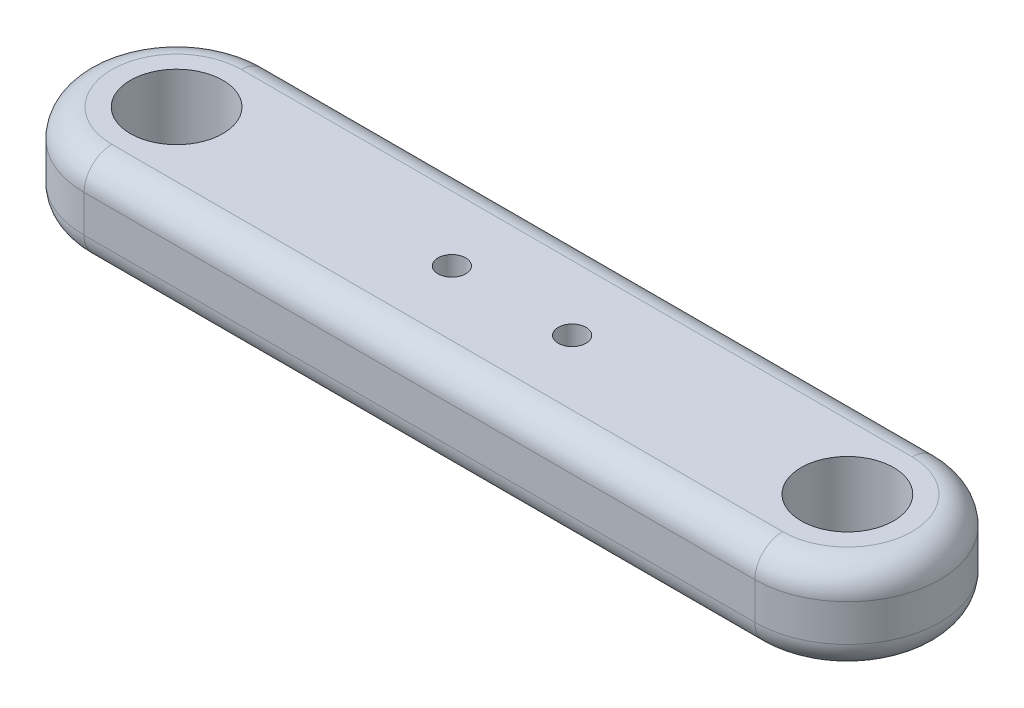
from build123d import *

# Parameters (mm, degrees)
SKETCH2_R           = 5
BOSS_EXTRUDE1_DEPTH = 10
FILLET1_R           = 3
BOSS_EXTRUDE2_DEPTH = 10
SKETCH4_R           = 1.5
CUT_EXTRUDE1_DEPTH  = 14


with BuildPart() as part:
    # Sketch2 → Boss-Extrude1 (new body)
    with BuildSketch(Plane(origin=(0, 0, 0), x_dir=(1, 0, 0), z_dir=(0, 1, 0))):
        with BuildLine():
            Line((36.25, 10), (-36.25, 10))
            ThreePointArc((-36.25, 10), (-46.25, 0), (-36.25, -10))
            Line((-36.25, -10), (36.25, -10))
            ThreePointArc((36.25, -10), (46.25, 0), (36.25, 10))
        make_face()
        with Locations((-36.25, 0)):
            Circle(SKETCH2_R, mode=Mode.SUBTRACT)
        with BuildLine():
            ThreePointArc((5, 0), (3.535533906, -3.535533906), (0, -5))
            ThreePointArc((0, -5), (-5, 0), (0, 5))
            ThreePointArc((0, 5), (3.535533906, 3.535533906), (5, 0))
        make_face(mode=Mode.SUBTRACT)
        with Locations((36.25, 0)):
            Circle(SKETCH2_R, mode=Mode.SUBTRACT)
    extrude(amount=BOSS_EXTRUDE1_DEPTH)

    # Fillet1
    fillet1_edges = [part.edges().sort_by_distance(p)[0] for p in [
        (46.25, 0, 0),
        (0, 0, 10),
        (0, 10, 10),
        (46.25, 10, 0),
        (0, 10, -10),
        (-46.25, 10, 0),
        (-46.25, 0, 0),
        (0, 0, -10),
    ]]
    fillet(fillet1_edges, radius=FILLET1_R)

    # Sketch3 → Boss-Extrude2 (add)
    with BuildSketch(Plane(origin=(0, 10, 0), x_dir=(1, 0, 0), z_dir=(0, 1, 0))):
        with BuildLine():
            Line((5, 0), (0, 0))
            Line((0, 0), (-5, 0))
            ThreePointArc((-5, 0), (0, -5), (5, 0))
        make_face()
        with BuildLine():
            Line((-5, 0), (0, 0))
            Line((0, 0), (5, 0))
            ThreePointArc((5, 0), (0, 5), (-5, 0))
        make_face()
    extrude(amount=-BOSS_EXTRUDE2_DEPTH)

    # Sketch4 → Cut-Extrude1 (cut)
    with BuildSketch(Plane(origin=(0, 10, 0), x_dir=(1, 0, 0), z_dir=(0, 1, 0))):
        with Locations((-6.5, 0)):
            Circle(SKETCH4_R)
        with Locations((6.5, 0)):
            Circle(SKETCH4_R)
    extrude(amount=-CUT_EXTRUDE1_DEPTH, mode=Mode.SUBTRACT)


solid = part.part
